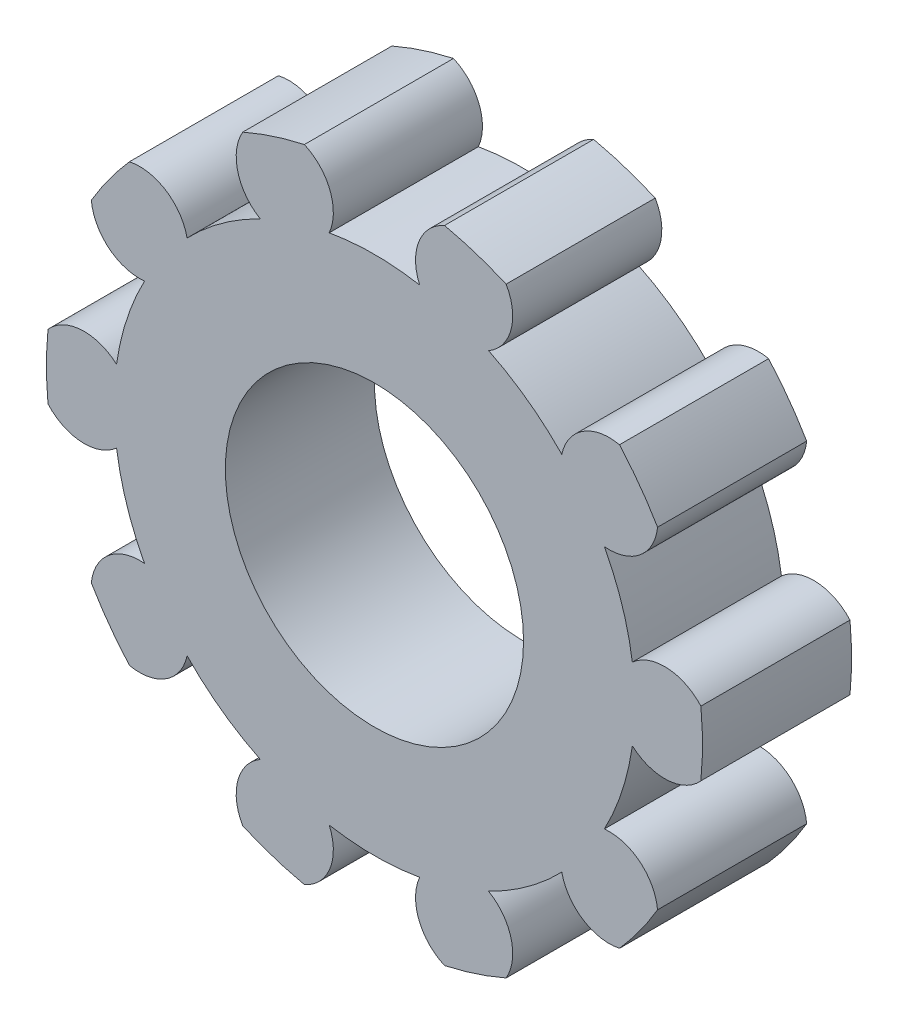
from build123d import *

# Parameters (mm, degrees)
SKETCH1_R           = 13.2
SKETCH1_R_2         = 6
BOSS_EXTRUDE1_DEPTH = 6
CUT_EXTRUDE1_DEPTH  = 7
CIRPATTERN1_COUNT   = 10


with BuildPart() as part:
    # Sketch1 → Boss-Extrude1 (new body)
    with BuildSketch(Plane.XY):
        Circle(SKETCH1_R)
        Circle(SKETCH1_R_2, mode=Mode.SUBTRACT)
    extrude(amount=BOSS_EXTRUDE1_DEPTH)

    # Sketch2 → Cut-Extrude1 (cut, through all)
    with BuildSketch(Plane.XY.offset(6)):
        with BuildLine():
            ThreePointArc((-2.819851171, 12.895287487), (0, 13.2), (2.819851171, 12.895287487))
            ThreePointArc((2.819851171, 12.895287487), (1.786491669, 11.814750525), (1.819851171, 10.32))
            ThreePointArc((1.819851171, 10.32), (0, 10.479229852), (-1.819851171, 10.32))
            ThreePointArc((-1.819851171, 10.32), (-1.786491669, 11.814750525), (-2.819851171, 12.895287487))
        make_face()
    cut_extrude1 = extrude(amount=-CUT_EXTRUDE1_DEPTH, mode=Mode.SUBTRACT)

    # CirPattern1: Cut-Extrude1 ×10 about axis
    cirpattern1_axis = Axis((0, 0, 0), (0, 0, 1))
    for i in range(1, CIRPATTERN1_COUNT):
        add(cut_extrude1.rotate(cirpattern1_axis, i * 360 / CIRPATTERN1_COUNT), mode=Mode.SUBTRACT)


solid = part.part
